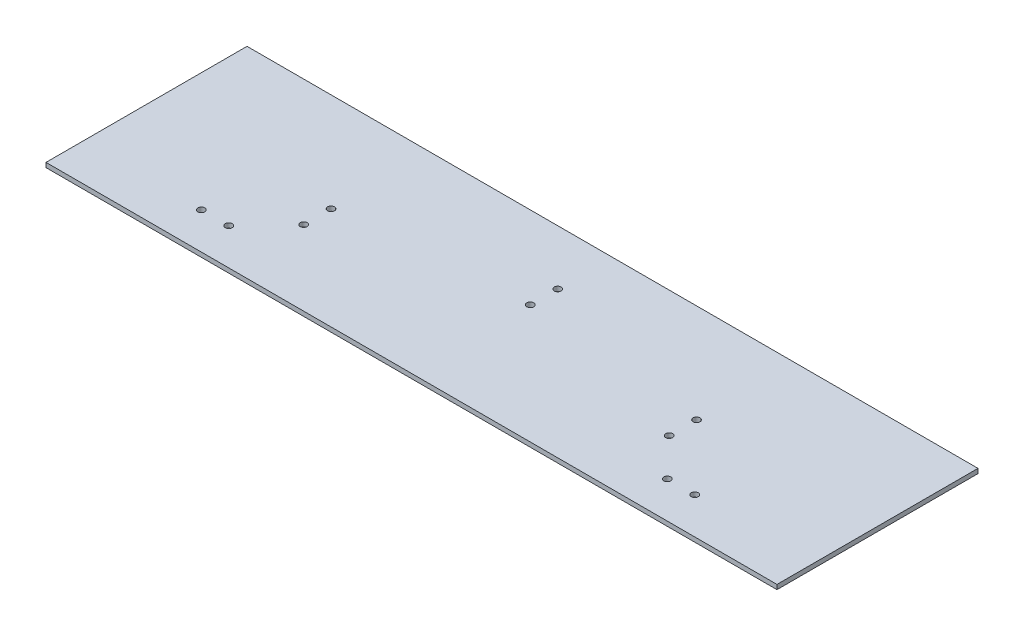
from build123d import *

# Parameters (mm, degrees)
SKETCH1_W           = 508
SKETCH1_H           = 139.7
BOSS_EXTRUDE1_DEPTH = 3.175
SKETCH2_R           = 2.413
CUT_EXTRUDE1_DEPTH  = 3.175


with BuildPart() as part:
    # Sketch1 → Boss-Extrude1 (new body)
    with BuildSketch(Plane(origin=(0, 0, 0), x_dir=(1, 0, 0), z_dir=(0, 1, 0))):
        with Locations((254, -69.85)):
            Rectangle(SKETCH1_W, SKETCH1_H)
    extrude(amount=BOSS_EXTRUDE1_DEPTH)

    # Sketch2 → Cut-Extrude1 (cut)
    with BuildSketch(Plane(origin=(0, 3.175, 0), x_dir=(1, 0, 0), z_dir=(0, 1, 0))):
        with Locations((82.55, -114.3)):
            Circle(SKETCH2_R)
        with Locations((101.6, -114.3)):
            Circle(SKETCH2_R)
        with Locations((127, -87.63)):
            Circle(SKETCH2_R)
        with Locations((127, -68.58)):
            Circle(SKETCH2_R)
        with Locations((254, -38.1)):
            Circle(SKETCH2_R)
        with Locations((254, -57.15)):
            Circle(SKETCH2_R)
        with Locations((425.45, -114.3)):
            Circle(SKETCH2_R)
        with Locations((406.4, -114.3)):
            Circle(SKETCH2_R)
        with Locations((381, -87.63)):
            Circle(SKETCH2_R)
        with Locations((381, -68.58)):
            Circle(SKETCH2_R)
    extrude(amount=-CUT_EXTRUDE1_DEPTH, mode=Mode.SUBTRACT)


solid = part.part
